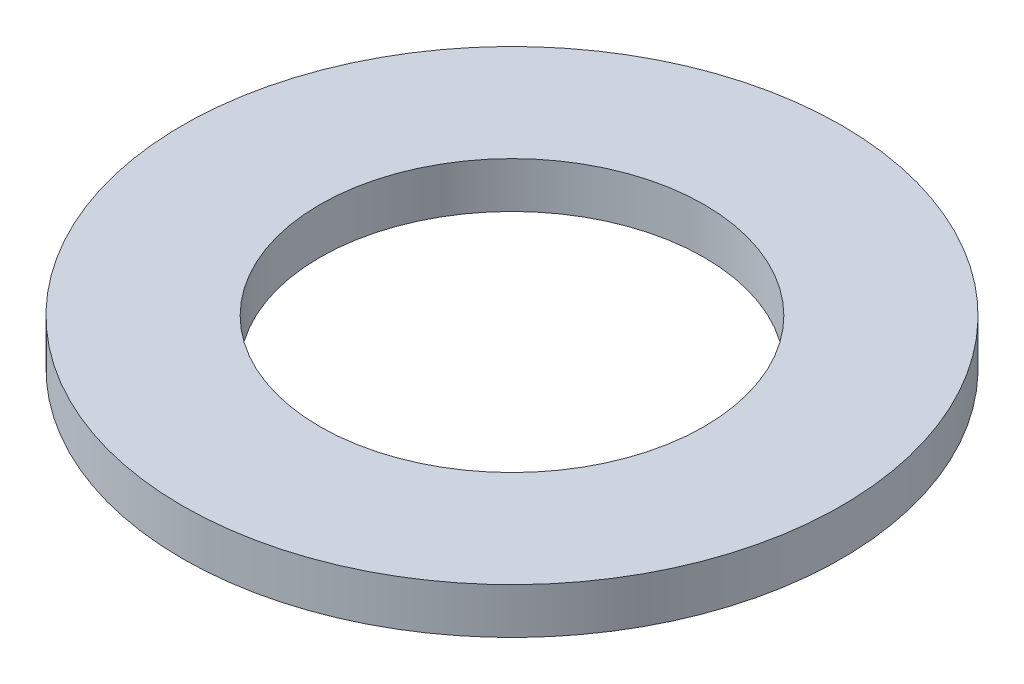
from build123d import *

# Parameters (mm, degrees)
SKETCH1_W = 3
SKETCH1_H = 1


with BuildPart() as part:
    # Sketch1 → Revolve1 (revolve)
    with BuildSketch(Plane.XY):
        with Locations((-5.7, 0.5)):
            Rectangle(SKETCH1_W, SKETCH1_H)
    revolve(axis=Axis((0, 0, 0), (0, 1, 0)))


solid = part.part
